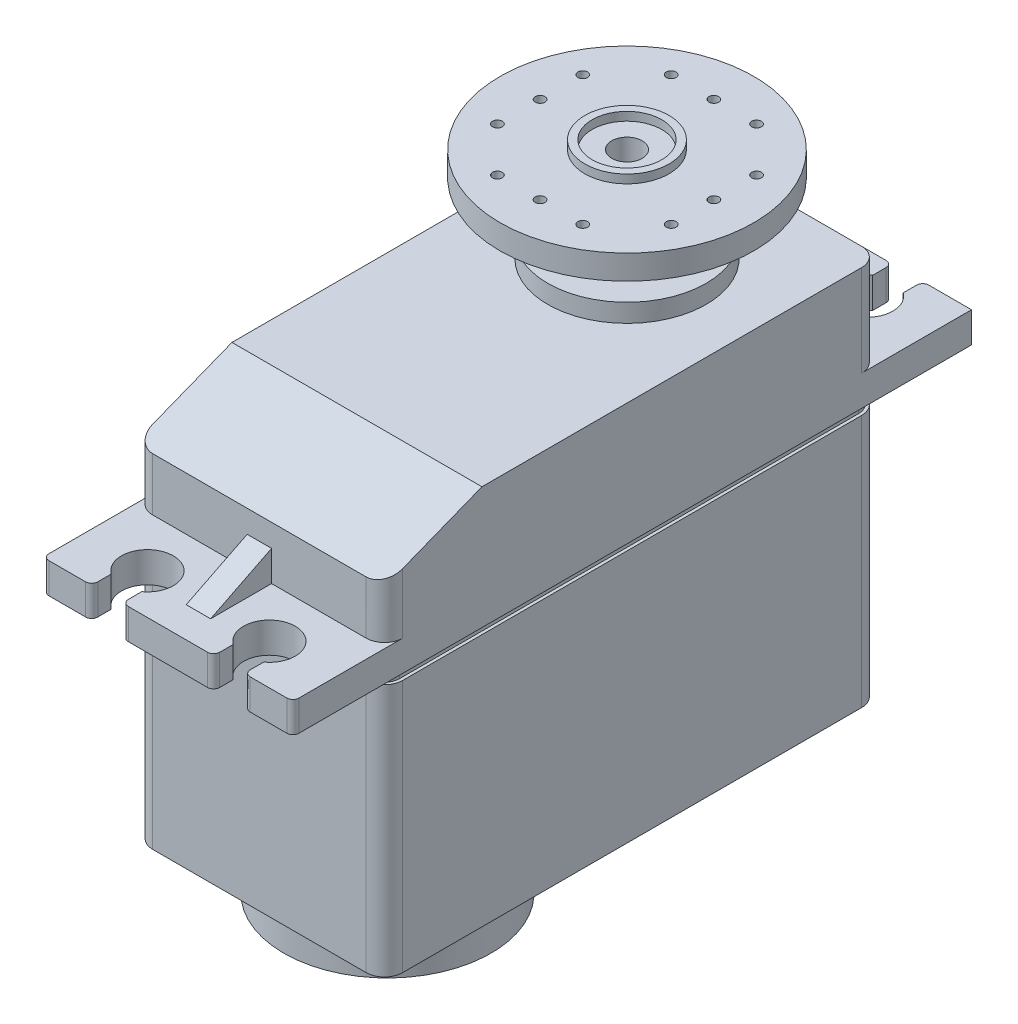
from build123d import *

# Parameters (mm, degrees)
SKETCH1_W           = 20.5
SKETCH1_H           = 40.64
BOSS_EXTRUDE1_DEPTH = 39.5
CUT_EXTRUDE1_DEPTH  = 21.5
SKETCH3_W           = 55.64
SKETCH3_H           = 2.5
BOSS_EXTRUDE2_DEPTH = 20.5
SKETCH4_R           = 2.125
CUT_EXTRUDE2_DEPTH  = 33
SKETCH5_W           = 2.5
SKETCH5_H           = 1.601534114
CUT_EXTRUDE3_DEPTH  = 33
BOSS_EXTRUDE3_DEPTH = 1
SKETCH7_R           = 6.5
BOSS_EXTRUDE4_DEPTH = 1.5
SKETCH8_R           = 2.9
BOSS_EXTRUDE5_DEPTH = 1.25
SKETCH9_R           = 4.445
BOSS_EXTRUDE6_DEPTH = 3
SKETCH10_R          = 10.4
BOSS_EXTRUDE7_DEPTH = 2
SKETCH11_R          = 1.25
CUT_EXTRUDE4_DEPTH  = 7.75
SKETCH12_R          = 3.45
SKETCH12_R_2        = 2.85
BOSS_EXTRUDE8_DEPTH = 0.7
SKETCH13_R          = 0.4
CUT_EXTRUDE5_DEPTH  = 2
FILLET1_R           = 1.5
FILLET2_R           = 0.5
CUT_EXTRUDE6_START  = -7.75
CUT_EXTRUDE6_DEPTH  = 0.5
CUT_EXTRUDE7_DEPTH  = 0.5
SKETCH16_W          = 50.439593456
SKETCH16_H          = 8.25
CUT_EXTRUDE8_DEPTH  = 21.65
SKETCH17_R          = 8.5
BOSS_EXTRUDE9_DEPTH = 4


with BuildPart() as part:
    # Sketch1 → Boss-Extrude1 (new body)
    with BuildSketch(Plane(origin=(0, 0, 0), x_dir=(1, 0, 0), z_dir=(0, 1, 0))):
        with Locations((0, 20.32)):
            Rectangle(SKETCH1_W, SKETCH1_H)
    extrude(amount=BOSS_EXTRUDE1_DEPTH)

    # Sketch2 → Cut-Extrude1 (cut, through all)
    with BuildSketch(Plane(origin=(10.25, 0, 0), x_dir=(0, 0, -1), z_dir=(1, 0, 0))):
        Polygon((0, 39.5), (0, 36.35), (8, 39.5), align=None)
    extrude(amount=-CUT_EXTRUDE1_DEPTH, mode=Mode.SUBTRACT)

    # Sketch3 → Boss-Extrude2 (add)
    with BuildSketch(Plane(origin=(10.25, 0, 0), x_dir=(0, 0, -1), z_dir=(1, 0, 0))):
        with Locations((20.32, 30.75)):
            Rectangle(SKETCH3_W, SKETCH3_H)
    extrude(amount=-BOSS_EXTRUDE2_DEPTH)

    # Sketch4 → Cut-Extrude2 (cut, through all)
    with BuildSketch(Plane(origin=(0, 32, 0), x_dir=(1, 0, 0), z_dir=(0, 1, 0))):
        with Locations((-5, -4.18)):
            Circle(SKETCH4_R)
        with Locations((5, -4.18)):
            Circle(SKETCH4_R)
        with Locations((5, 44.82)):
            Circle(SKETCH4_R)
        with Locations((-5, 44.82)):
            Circle(SKETCH4_R)
    extrude(amount=-CUT_EXTRUDE2_DEPTH, mode=Mode.SUBTRACT)

    # Sketch5 → Cut-Extrude3 (cut, through all)
    with BuildSketch(Plane(origin=(0, 32, 0), x_dir=(1, 0, 0), z_dir=(0, 1, 0))):
        with Locations((5, -6.699232943)):
            Rectangle(SKETCH5_W, SKETCH5_H)
        with Locations((-5, -6.699232943)):
            Rectangle(SKETCH5_W, SKETCH5_H)
        with Locations((-5, 47.339232943)):
            Rectangle(SKETCH5_W, SKETCH5_H)
        with Locations((5, 47.339232943)):
            Rectangle(SKETCH5_W, SKETCH5_H)
    extrude(amount=-CUT_EXTRUDE3_DEPTH, mode=Mode.SUBTRACT)

    # Sketch6 → Boss-Extrude3 (add, symmetric)
    with BuildSketch(Plane(origin=(0, 0, 0), x_dir=(0, 0, -1), z_dir=(1, 0, 0))):
        Polygon((0, 32), (-5, 32), (0, 34.5), align=None)
        Polygon((40.64, 32), (45.64, 32), (40.64, 34.5), align=None)
    extrude(amount=BOSS_EXTRUDE3_DEPTH, both=True)

    # Sketch7 → Boss-Extrude4 (add)
    with BuildSketch(Plane(origin=(0, 39.5, 0), x_dir=(1, 0, 0), z_dir=(0, 1, 0))):
        with Locations((0, 30.14)):
            Circle(SKETCH7_R)
    extrude(amount=BOSS_EXTRUDE4_DEPTH)

    # Sketch8 → Boss-Extrude5 (add)
    with BuildSketch(Plane(origin=(0, 41, 0), x_dir=(1, 0, 0), z_dir=(0, 1, 0))):
        with Locations((0, 30.14)):
            Circle(SKETCH8_R)
    extrude(amount=BOSS_EXTRUDE5_DEPTH)

    # Sketch9 → Boss-Extrude6 (add)
    with BuildSketch(Plane(origin=(0, 42.25, 0), x_dir=(1, 0, 0), z_dir=(0, 1, 0))):
        with Locations((0, 30.14)):
            Circle(SKETCH9_R)
    extrude(amount=BOSS_EXTRUDE6_DEPTH)

    # Sketch10 → Boss-Extrude7 (add)
    with BuildSketch(Plane(origin=(0, 45.25, 0), x_dir=(1, 0, 0), z_dir=(0, 1, 0))):
        with Locations((0, 30.14)):
            Circle(SKETCH10_R)
    extrude(amount=BOSS_EXTRUDE7_DEPTH)

    # Sketch11 → Cut-Extrude4 (cut)
    with BuildSketch(Plane(origin=(0, 47.25, 0), x_dir=(1, 0, 0), z_dir=(0, 1, 0))):
        with Locations((0, 30.14)):
            Circle(SKETCH11_R)
    extrude(amount=-CUT_EXTRUDE4_DEPTH, mode=Mode.SUBTRACT)

    # Sketch12 → Boss-Extrude8 (add)
    with BuildSketch(Plane(origin=(0, 47.25, 0), x_dir=(1, 0, 0), z_dir=(0, 1, 0))):
        with Locations((0, 30.14)):
            Circle(SKETCH12_R)
        with Locations((0, 30.14)):
            Circle(SKETCH12_R_2, mode=Mode.SUBTRACT)
    extrude(amount=BOSS_EXTRUDE8_DEPTH)

    # Sketch13 → Cut-Extrude5 (cut)
    with BuildSketch(Plane(origin=(0, 47.25, 0), x_dir=(1, 0, 0), z_dir=(0, 1, 0))):
        with Locations((0, 37.265)):
            Circle(SKETCH13_R)
        with Locations((3.5, 37.265)):
            Circle(SKETCH13_R)
        with Locations((-3.5, 37.265)):
            Circle(SKETCH13_R)
        with Locations((7.125, 26.64)):
            Circle(SKETCH13_R)
        with Locations((7.125, 30.14)):
            Circle(SKETCH13_R)
        with Locations((7.125, 33.64)):
            Circle(SKETCH13_R)
        with Locations((-3.5, 23.015)):
            Circle(SKETCH13_R)
        with Locations((0, 23.015)):
            Circle(SKETCH13_R)
        with Locations((3.5, 23.015)):
            Circle(SKETCH13_R)
        with Locations((-7.125, 33.64)):
            Circle(SKETCH13_R)
        with Locations((-7.125, 30.14)):
            Circle(SKETCH13_R)
        with Locations((-7.125, 26.64)):
            Circle(SKETCH13_R)
    extrude(amount=-CUT_EXTRUDE5_DEPTH, mode=Mode.SUBTRACT)

    # Fillet1
    fillet1_edges = [part.edges().sort_by_distance(p)[0] for p in [
        (10.25, 34.175, 0),
        (-10.25, 34.175, 0),
        (-10.25, 14.75, -40.64),
        (10.25, 14.75, -40.64),
        (10.25, 14.75, 0),
        (-10.25, 14.75, 0),
        (-10.25, 35.75, -40.64),
        (10.25, 35.75, -40.64),
    ]]
    fillet(fillet1_edges, radius=FILLET1_R)

    # Fillet2
    fillet2_edges = [part.edges().sort_by_distance(p)[0] for p in [
        (-3.75, 30.75, -48.14),
        (-6.25, 30.75, -48.14),
        (3.75, 30.75, -48.14),
        (6.25, 30.75, -48.14),
        (10.25, 30.75, 7.5),
        (-10.25, 30.75, 7.5),
        (-10.25, 30.75, -48.14),
        (-3.75, 30.75, 7.5),
        (-6.25, 30.75, 7.5),
        (3.75, 30.75, 7.5),
        (6.25, 30.75, 7.5),
    ]]
    fillet(fillet2_edges, radius=FILLET2_R)

    # Sketch14 → Cut-Extrude6 (cut)
    with BuildSketch(Plane.XZ.offset(CUT_EXTRUDE6_START)):
        with BuildLine():
            Line((-8.75, -40.64), (8.75, -40.64))
            ThreePointArc((8.75, -40.64), (9.810660172, -40.200660172), (10.25, -39.14))
            Line((10.25, -39.14), (10.25, -1.5))
            ThreePointArc((10.25, -1.5), (9.810660172, -0.439339828), (8.75, 0))
            Line((8.75, 0), (-8.75, 0))
            ThreePointArc((-8.75, 0), (-9.810660172, -0.439339828), (-10.25, -1.5))
            Line((-10.25, -1.5), (-10.25, -39.14))
            ThreePointArc((-10.25, -39.14), (-9.810660172, -40.200660172), (-8.75, -40.64))
        make_face()
        with BuildLine():
            Line((8.75, -0.25), (-8.75, -0.25))
            ThreePointArc((-8.75, -0.25), (-9.633883476, -0.616116524), (-10, -1.5))
            Line((-10, -1.5), (-10, -39.14))
            ThreePointArc((-10, -39.14), (-9.633883476, -40.023883476), (-8.75, -40.39))
            Line((-8.75, -40.39), (8.75, -40.39))
            ThreePointArc((8.75, -40.39), (9.633883476, -40.023883476), (10, -39.14))
            Line((10, -39.14), (10, -1.5))
            ThreePointArc((10, -1.5), (9.633883476, -0.616116524), (8.75, -0.25))
        make_face(mode=Mode.SUBTRACT)
    extrude(amount=-CUT_EXTRUDE6_DEPTH, mode=Mode.SUBTRACT)

    # Sketch15 → Cut-Extrude7 (cut)
    with BuildSketch(Plane.XZ.offset(-29.5)):
        with BuildLine():
            Line((-8.75, -40.64), (8.75, -40.64))
            ThreePointArc((8.75, -40.64), (9.810660172, -40.200660172), (10.25, -39.14))
            Line((10.25, -39.14), (10.25, -1.5))
            ThreePointArc((10.25, -1.5), (9.810660172, -0.439339828), (8.75, 0))
            Line((8.75, 0), (-8.75, 0))
            ThreePointArc((-8.75, 0), (-9.810660172, -0.439339828), (-10.25, -1.5))
            Line((-10.25, -1.5), (-10.25, -39.14))
            ThreePointArc((-10.25, -39.14), (-9.810660172, -40.200660172), (-8.75, -40.64))
        make_face()
        with BuildLine():
            Line((10, -39.14), (10, -1.5))
            ThreePointArc((10, -1.5), (9.633883476, -0.616116524), (8.75, -0.25))
            Line((8.75, -0.25), (-8.75, -0.25))
            ThreePointArc((-8.75, -0.25), (-9.633883476, -0.616116524), (-10, -1.5))
            Line((-10, -1.5), (-10, -39.14))
            ThreePointArc((-10, -39.14), (-9.633883476, -40.023883476), (-8.75, -40.39))
            Line((-8.75, -40.39), (8.75, -40.39))
            ThreePointArc((8.75, -40.39), (9.633883476, -40.023883476), (10, -39.14))
        make_face(mode=Mode.SUBTRACT)
    extrude(amount=CUT_EXTRUDE7_DEPTH, mode=Mode.SUBTRACT)

    # Sketch16 → Cut-Extrude8 (cut, through all)
    with BuildSketch(Plane(origin=(10.25, 0, 0), x_dir=(0, 0, -1), z_dir=(1, 0, 0))):
        with Locations((25.219796728, 4.125)):
            Rectangle(SKETCH16_W, SKETCH16_H)
    extrude(amount=-CUT_EXTRUDE8_DEPTH, mode=Mode.SUBTRACT)

    # Sketch17 → Boss-Extrude9 (add)
    with BuildSketch(Plane.XZ.offset(-8.25)):
        with Locations((0, -10.5)):
            Circle(SKETCH17_R)
    extrude(amount=BOSS_EXTRUDE9_DEPTH)


solid = part.part
